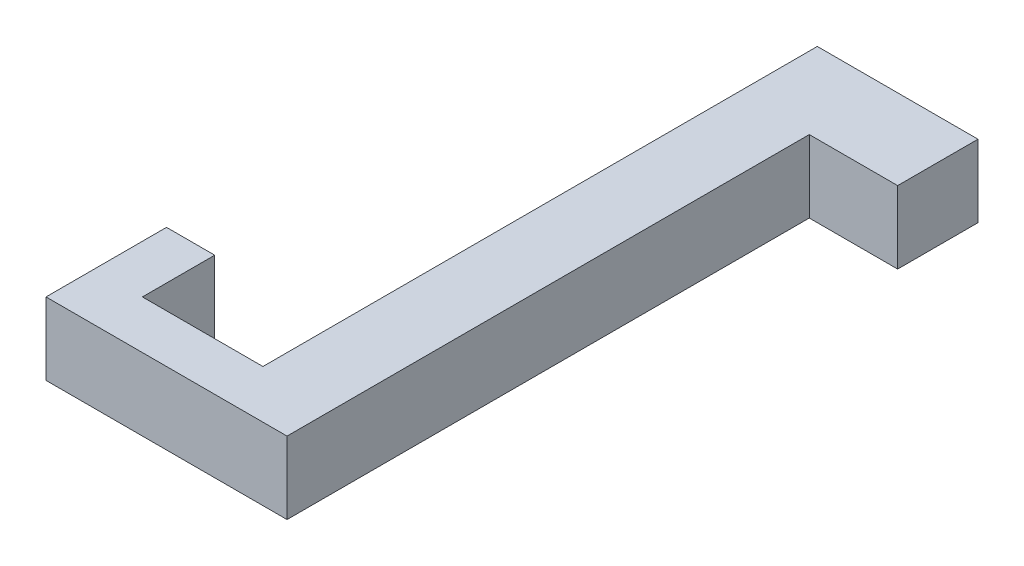
from build123d import *

# Parameters (mm, degrees)
BOSS_EXTRUDE1_DEPTH = 4.5


with BuildPart() as part:
    # Sketch2 → Boss-Extrude1 (new body)
    with BuildSketch(Plane(origin=(0, 0, 0), x_dir=(1, 0, 0), z_dir=(0, 1, 0))):
        Polygon((0, -16.25), (-15, -16.25), (-15, -8.75), (-12, -8.75), (-12, -13.25), (-4.5, -13.25), (-4.5, 21.25), (5.5, 21.25), (5.5, 16.25), (0, 16.25), align=None)
    extrude(amount=BOSS_EXTRUDE1_DEPTH)


solid = part.part
